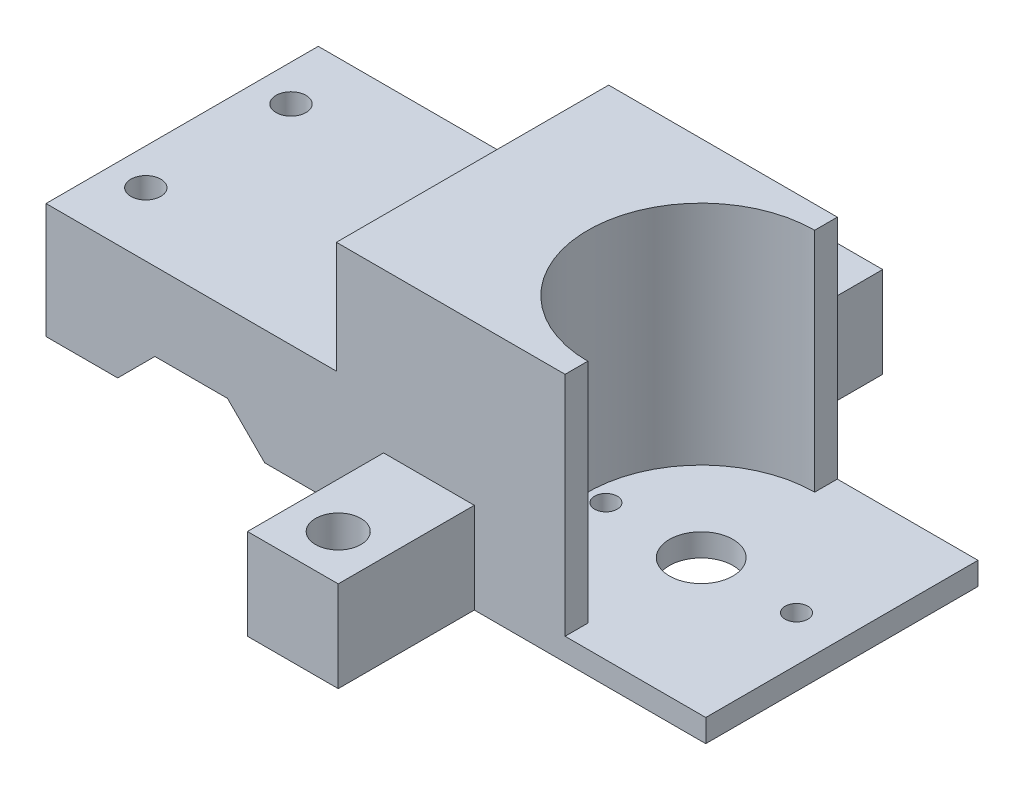
from build123d import *

# Parameters (mm, degrees)
BOSS_EXTRUDE1_DEPTH  = 15
SKETCH2_R            = 1.65
CUT_EXTRUDE1_DEPTH   = 12.7
SKETCH12_W           = 30
SKETCH12_H           = 25
BOSS_EXTRUDE9_DEPTH  = 25.2
CUT_EXTRUDE2_DEPTH   = 25
SKETCH14_W           = 35.5
SKETCH14_H           = 30
SKETCH14_R           = 3.5
SKETCH14_R_2         = 1.25
BOSS_EXTRUDE10_DEPTH = 2.5
SKETCH15_W           = 10
SKETCH15_H           = 15
SKETCH15_R           = 2.5
BOSS_EXTRUDE11_DEPTH = 10


with BuildPart() as part:
    # Sketch1 → Boss-Extrude1 (new body, symmetric)
    with BuildSketch(Plane.XY):
        Polygon((-4, 4.101219331), (4, 4.101219331), (8.101219331, 0), (16, 0), (16, 12.7), (-16, 12.7), (-16, 0), (-8.101219331, 0), align=None)
    extrude(amount=BOSS_EXTRUDE1_DEPTH, both=True)

    # Sketch2 → Cut-Extrude1 (cut)
    with BuildSketch(Plane(origin=(0, 12.7, 0), x_dir=(1, 0, 0), z_dir=(0, 1, 0))):
        with Locations((12, 8)):
            Circle(SKETCH2_R)
        with Locations((12, -8)):
            Circle(SKETCH2_R)
        with Locations((-12, -8)):
            Circle(SKETCH2_R)
        with Locations((-12, 8)):
            Circle(SKETCH2_R)
    extrude(amount=-CUT_EXTRUDE1_DEPTH, mode=Mode.SUBTRACT)

    # Sketch12 → Boss-Extrude9 (add)
    with BuildSketch(Plane(origin=(16, 0, 0), x_dir=(0, 0, -1), z_dir=(1, 0, 0))):
        with Locations((0, 12.5)):
            Rectangle(SKETCH12_W, SKETCH12_H)
    extrude(amount=BOSS_EXTRUDE9_DEPTH)

    # Sketch13 → Cut-Extrude2 (cut)
    with BuildSketch(Plane(origin=(0, 25, 0), x_dir=(1, 0, 0), z_dir=(0, 1, 0))):
        with BuildLine():
            Line((41.2, 12.5), (41.2, -12.5))
            ThreePointArc((41.2, -12.5), (28.7, 0), (41.2, 12.5))
        make_face()
    extrude(amount=-CUT_EXTRUDE2_DEPTH, mode=Mode.SUBTRACT)

    # Sketch14 → Boss-Extrude10 (add)
    with BuildSketch(Plane.XZ):
        with Locations((38.95, 0)):
            Rectangle(SKETCH14_W, SKETCH14_H)
        with Locations((41.2, 0)):
            Circle(SKETCH14_R, mode=Mode.SUBTRACT)
        with Locations((51.7, 0)):
            Circle(SKETCH14_R_2, mode=Mode.SUBTRACT)
        with Locations((30.7, 0)):
            Circle(SKETCH14_R_2, mode=Mode.SUBTRACT)
    extrude(amount=BOSS_EXTRUDE10_DEPTH)

    # Sketch15 → Boss-Extrude11 (add)
    with BuildSketch(Plane.XZ.offset(2.5)):
        with Locations((26.2, 22.5)):
            Rectangle(SKETCH15_W, SKETCH15_H)
        with Locations((26.2, 25)):
            Circle(SKETCH15_R, mode=Mode.SUBTRACT)
        with Locations((26.2, -22.5)):
            Rectangle(SKETCH15_W, SKETCH15_H)
        with Locations((26.2, -25)):
            Circle(SKETCH15_R, mode=Mode.SUBTRACT)
    extrude(amount=-BOSS_EXTRUDE11_DEPTH)


solid = part.part
